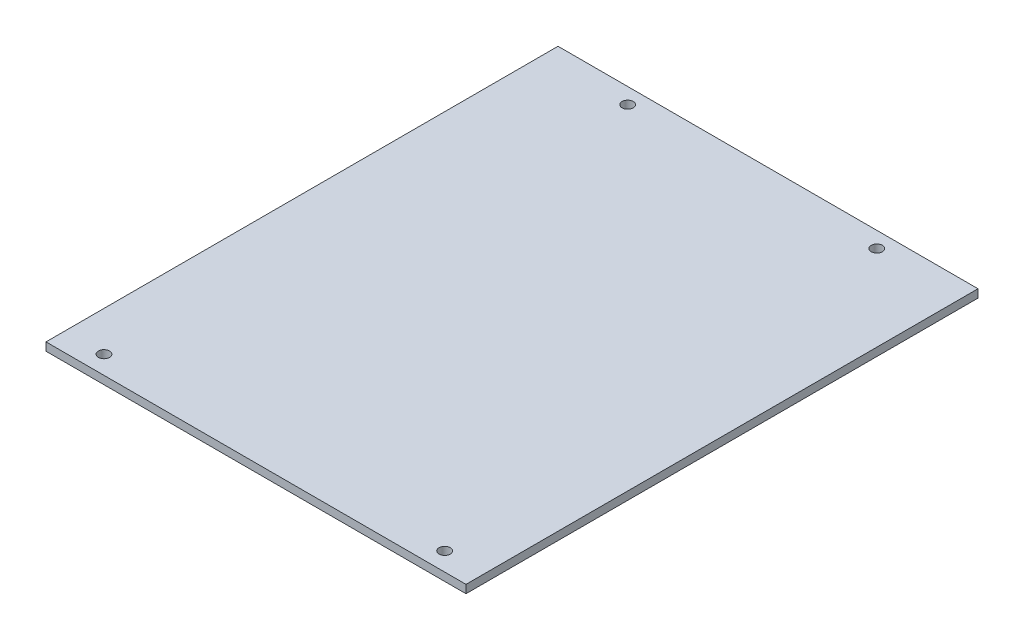
from build123d import *

# Parameters (mm, degrees)
BOSS_EXTRUDE1_DEPTH            = 1.6
F_2_2_2_2_DIAMETER_HOLE2_D     = 2.2
F_2_2_2_2_DIAMETER_HOLE1_D     = 2.2
F_2_2_2_2_DIAMETER_HOLE1_DEPTH = 2
SKETCH7_W                      = 0.2
SKETCH7_H                      = 100.7
EXTRUDE1_DEPTH                 = 2.6


with BuildPart() as part:
    # Sketch1 → Boss-Extrude1 (new body)
    with BuildSketch(Plane(origin=(0, 0, 0), x_dir=(1, 0, 0), z_dir=(0, 1, 0))):
        Polygon((65.24, 10.562547362), (65.24, -54.937452638), (65.24, -68.137452638), (-17.76, -68.137452638), (-17.76, -46.137452638), (-17.76, 19.362547362), (-17.76, 32.562547362), (65.24, 32.562547362), align=None)
    extrude(amount=BOSS_EXTRUDE1_DEPTH)

    # Ø2.2 (2.2) Diameter Hole2 (through all)
    with Locations(Plane(origin=(0, 1.6, 0), x_dir=(1, 0, 0), z_dir=(0, 1, 0))):
        with Locations((-0.76, 29.462547362), (48.24, 29.462547362)):
            Hole(F_2_2_2_2_DIAMETER_HOLE2_D / 2)

    # Ø2.2 (2.2) Diameter Hole1
    with Locations(Plane(origin=(0, 1.6, 0), x_dir=(1, 0, 0), z_dir=(0, 1, 0))):
        with Locations((-9.76, -64.537452638), (57.24, -64.537452638)):
            Hole(F_2_2_2_2_DIAMETER_HOLE1_D / 2, depth=F_2_2_2_2_DIAMETER_HOLE1_DEPTH)

    # Sketch7 → Extrude1 (cut, through all)
    with BuildSketch(Plane.XZ):
        with Locations((-17.66, 17.787452638)):
            Rectangle(SKETCH7_W, SKETCH7_H)
        with Locations((65.14, 17.787452638)):
            Rectangle(SKETCH7_W, SKETCH7_H)
    extrude(amount=-EXTRUDE1_DEPTH, mode=Mode.SUBTRACT)


solid = part.part
